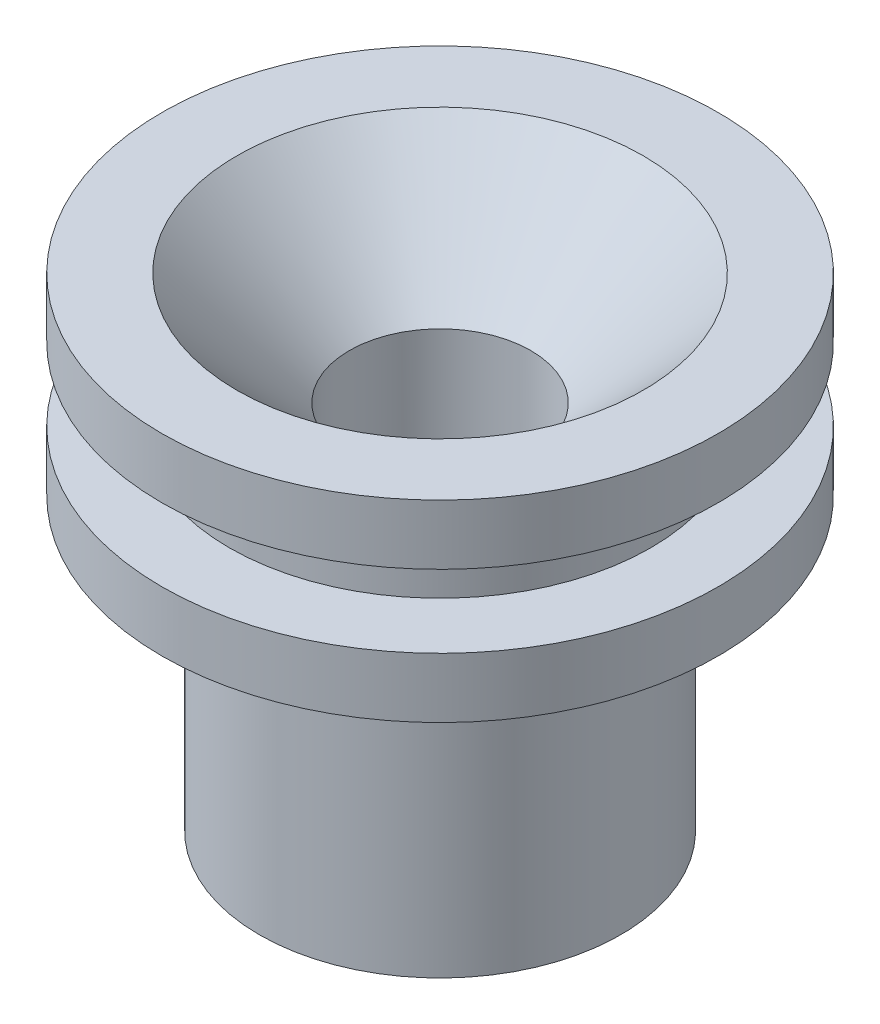
from build123d import *

# Parameters (mm, degrees)
SKETCH2_R          = 3.0734
CUT_EXTRUDE1_DEPTH = 15.494
SKETCH3_R          = 1.5494
CUT_EXTRUDE2_DEPTH = 22.099099812
CHAMFER1_SIZE      = 3.81


with BuildPart() as part:
    # Sketch1 → Revolve1 (revolve)
    with BuildSketch(Plane.XY):
        Polygon((0, 0), (6.1214, 0), (6.1214, 9.8298), (9.4234, 9.8298), (9.4234, 11.8618), (7.1374, 11.8618), (7.1374, 14.3256), (9.4234, 14.3256), (9.4234, 16.3576), (0, 16.3576), (0, 9.8298), align=None)
    revolve(axis=Axis((0, 16.3576, 0), (0, -1, 0)))

    # Sketch2 → Cut-Extrude1 (cut)
    with BuildSketch(Plane(origin=(0, 16.3576, 0), x_dir=(1, 0, 0), z_dir=(0, 1, 0))):
        Circle(SKETCH2_R)
    extrude(amount=-CUT_EXTRUDE1_DEPTH, mode=Mode.SUBTRACT)

    # Sketch3 → Cut-Extrude2 (cut, through all)
    with BuildSketch(Plane.XZ):
        Circle(SKETCH3_R)
    extrude(amount=-CUT_EXTRUDE2_DEPTH, mode=Mode.SUBTRACT)

    # Chamfer1
    chamfer1_edges = [part.edges().sort_by_distance(p)[0] for p in [
        (-3.0734, 16.3576, 0),
    ]]
    chamfer(chamfer1_edges, length=CHAMFER1_SIZE)


solid = part.part
